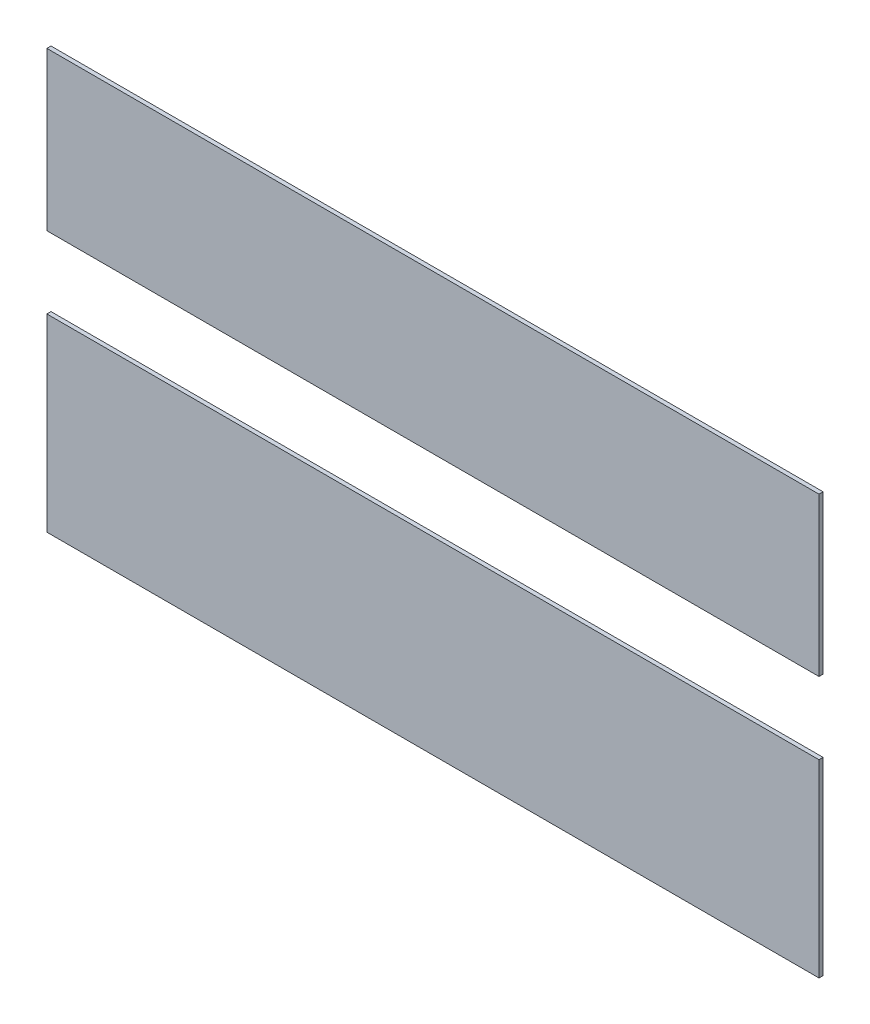
from build123d import *

# Parameters (mm, degrees)
BOSS_EXTRUDE1_DEPTH = 2
SKETCH3_W           = 374.997816797
SKETCH3_H           = 35
CUT_EXTRUDE2_DEPTH  = 10


with BuildPart() as part:
    # Sketch1 → Boss-Extrude1 (new body)
    with BuildSketch(Plane.XY):
        Polygon((10323.34448258, 14405.557974035), (9969.84448258, 14405.557974035), (9968.34448258, 14405.557974035), (9968.34448258, 14202.06060864), (10343.342299377, 14202.058856827), (10343.342299377, 14405.557974035), align=None)
    extrude(amount=BOSS_EXTRUDE1_DEPTH)

    # Sketch3 → Cut-Extrude2 (cut)
    with BuildSketch(Plane.XY.offset(2)):
        with Locations((10155.843390978, 14311.357974035)):
            Rectangle(SKETCH3_W, SKETCH3_H)
    extrude(amount=-CUT_EXTRUDE2_DEPTH, mode=Mode.SUBTRACT)


solid = part.part
